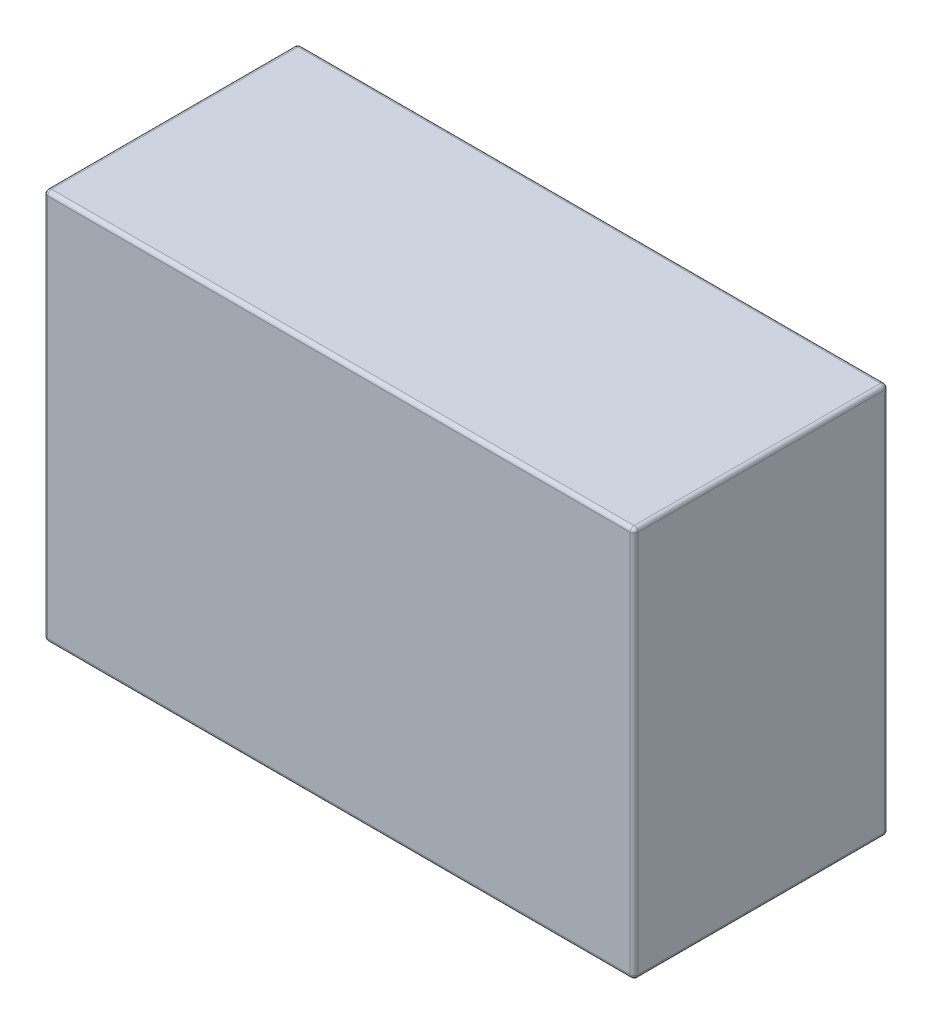
from build123d import *

# Parameters (mm, degrees)
SKETCH1_W           = 151
SKETCH1_H           = 65
BOSS_EXTRUDE1_DEPTH = 100
FILLET1_R           = 1


with BuildPart() as part:
    # Sketch1 → Boss-Extrude1 (new body)
    with BuildSketch(Plane(origin=(0, 0, 0), x_dir=(1, 0, 0), z_dir=(0, 1, 0))):
        Rectangle(SKETCH1_W, SKETCH1_H)
    extrude(amount=BOSS_EXTRUDE1_DEPTH)

    # Fillet1
    fillet1_edges = [part.edges().sort_by_distance(p)[0] for p in [
        (-75.5, 100, 0),
        (0, 100, 32.5),
        (75.5, 100, 0),
        (0, 0, 32.5),
        (-75.5, 0, 0),
        (0, 0, -32.5),
        (75.5, 0, 0),
        (75.5, 50, 32.5),
        (-75.5, 50, 32.5),
        (-75.5, 50, -32.5),
        (75.5, 50, -32.5),
        (0, 100, -32.5),
    ]]
    fillet(fillet1_edges, radius=FILLET1_R)


solid = part.part
